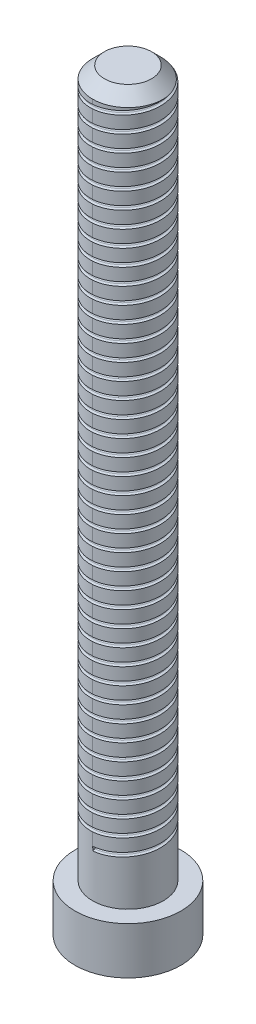
from build123d import *

# Parameters (mm, degrees)
SKETCH1_R              = 2.25
BOSS_EXTRUDE1_DEPTH    = 32
SKETCH2_OUTSIDE_W      = 13.026
SKETCH2_OUTSIDE_H      = 13.026
SKETCH2_OUTSIDE_R      = 1.5
CUT_EXTRUDE1_DEPTH     = 30
CHAMFER1_SIZE          = 0.5
CUT_SWEEP1_PITCH       = 0.7
CUT_SWEEP1_HEIGHT      = 28
CUT_SWEEP1_RADIUS      = 1.5
CUT_SWEEP1_START_ANGLE = 180
CUT_EXTRUDE2_DEPTH     = 1.5


with BuildPart() as part:
    # Sketch1 → Boss-Extrude1 (new body)
    with BuildSketch(Plane(origin=(0, 0, 0), x_dir=(1, 0, 0), z_dir=(0, 1, 0))):
        with Locations(Location((0, 0, 0), (0, 0, 270))):
            Circle(SKETCH1_R)
    extrude(amount=BOSS_EXTRUDE1_DEPTH)

    # Sketch2 outside → Cut-Extrude1 (cut)
    with BuildSketch(Plane(origin=(0, 32, 0), x_dir=(1, 0, 0), z_dir=(0, 1, 0))):
        Rectangle(SKETCH2_OUTSIDE_W, SKETCH2_OUTSIDE_H)
        with Locations(Location((0, 0, 0), (0, 0, 270))):
            Circle(SKETCH2_OUTSIDE_R, mode=Mode.SUBTRACT)
    extrude(amount=-CUT_EXTRUDE1_DEPTH, mode=Mode.SUBTRACT)

    # Chamfer1
    chamfer1_edges = [part.edges().sort_by_distance(p)[0] for p in [
        (0, 32, -1.5),
    ]]
    chamfer(chamfer1_edges, length=CHAMFER1_SIZE)

    # Cut-Sweep1: sweep along a helix
    with BuildLine() as cut_sweep1_path:
        add(Helix(CUT_SWEEP1_PITCH, CUT_SWEEP1_HEIGHT, CUT_SWEEP1_RADIUS, center=(0, 32, 0), direction=(0, -1, 0), mode=Mode.PRIVATE).rotate(Axis((0, 32, 0), (0, -1, 0)), CUT_SWEEP1_START_ANGLE))
    # Sketch7 → Cut-Sweep1 (sweep, cut)
    with BuildSketch(Plane(origin=(0, 32, 1.5), x_dir=(0, 0, 1), z_dir=(-0.997253171, -0.074068293, 0))):
        with BuildLine():
            Line((-0.081023547, -0.030253267), (0.549038106, 0.274742329))
            Line((0.549038106, 0.274742329), (0.549038106, -0.425257671))
            Line((0.549038106, -0.425257671), (-0.081023547, -0.120262075))
            ThreePointArc((-0.081023547, -0.120262075), (-0.109238147, -0.075257671), (-0.081023547, -0.030253267))
        make_face()
    sweep(path=cut_sweep1_path.line, is_frenet=True, mode=Mode.SUBTRACT)

    # Sketch8 → Cut-Extrude2 (cut)
    with BuildSketch(Plane.XZ):
        Polygon((1.154700538, 0), (0.577350269, 1), (-0.577350269, 1), (-1.154700538, 0), (-0.577350269, -1), (0.577350269, -1), align=None)
    extrude(amount=-CUT_EXTRUDE2_DEPTH, mode=Mode.SUBTRACT)


solid = part.part
